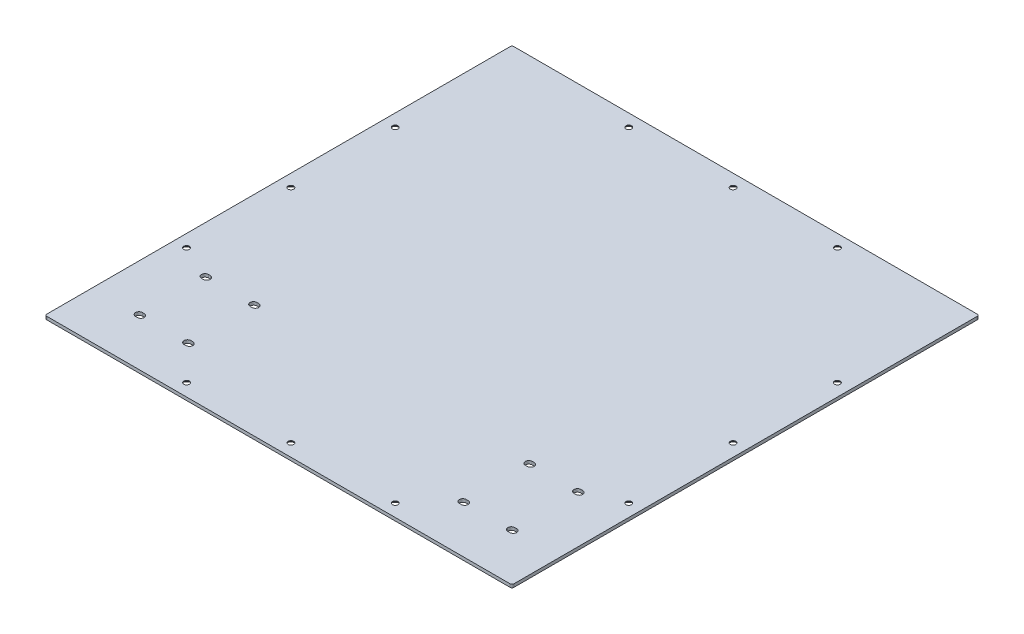
from build123d import *

# Parameters (mm, degrees)
SKETCH1_W                                      = 750
SKETCH1_H                                      = 750
BOSS_EXTRUDE1_DEPTH                            = 5
CSK_FOR_M8_FLAT_HEAD_MACHINE_SCREW1_AT_2_COUNT = 2
CSK_FOR_M8_FLAT_HEAD_MACHINE_SCREW1_AT_2_PITCH = 167.5
CSK_FOR_M8_FLAT_HEAD_MACHINE_SCREW1_AT_3_COUNT = 2
CSK_FOR_M8_FLAT_HEAD_MACHINE_SCREW1_AT_3_PITCH = 167.5
CSK_FOR_M8_FLAT_HEAD_MACHINE_SCREW1_AT_4_COUNT = 2
CSK_FOR_M8_FLAT_HEAD_MACHINE_SCREW1_AT_4_PITCH = 502.045814642
CSK_FOR_M8_FLAT_HEAD_MACHINE_SCREW1_AT_5_COUNT = 2
CSK_FOR_M8_FLAT_HEAD_MACHINE_SCREW1_AT_5_PITCH = 631.689203644
CSK_FOR_M8_FLAT_HEAD_MACHINE_SCREW1_AT_6_COUNT = 2
CSK_FOR_M8_FLAT_HEAD_MACHINE_SCREW1_AT_6_PITCH = 401.473847218
FILLET1_R                                      = 3
CUT_EXTRUDE1_DEPTH                             = 6
LPATTERN1_COUNT                                = 2
LPATTERN1_PITCH                                = 520


with BuildPart() as part:
    # Sketch1 → Boss-Extrude1 (new body)
    with BuildSketch(Plane(origin=(0, 0, 0), x_dir=(1, 0, 0), z_dir=(0, 1, 0))):
        with Locations((375, -375)):
            Rectangle(SKETCH1_W, SKETCH1_H)
    extrude(amount=BOSS_EXTRUDE1_DEPTH)

    # Sketch4 → CSK for M8 Flat Head Machine Screw1 (revolve, cut)
    with BuildSketch(Plane(origin=(20, 0, 375), x_dir=(0, 0, -1), z_dir=(1, 0, 0))):
        Polygon((0, 0), (0, 5), (4.5, 5), (4.5, 4.15), (8.65, 0), align=None)
    csk_for_m8_flat_head_machine_screw1 = revolve(axis=Axis((20, -6.35, 375), (0, 1, 0)), mode=Mode.SUBTRACT)

    # CSK for M8 Flat Head Machine Screw1 at 2: CSK for M8 Flat Head Machine Screw1 ×2
    with Locations(*[(0, 0, i * CSK_FOR_M8_FLAT_HEAD_MACHINE_SCREW1_AT_2_PITCH) for i in range(1, CSK_FOR_M8_FLAT_HEAD_MACHINE_SCREW1_AT_2_COUNT)]):
        add(csk_for_m8_flat_head_machine_screw1, mode=Mode.SUBTRACT)

    # CSK for M8 Flat Head Machine Screw1 at 3: CSK for M8 Flat Head Machine Screw1 ×2
    with Locations(*[(0, 0, -i * CSK_FOR_M8_FLAT_HEAD_MACHINE_SCREW1_AT_3_PITCH) for i in range(1, CSK_FOR_M8_FLAT_HEAD_MACHINE_SCREW1_AT_3_COUNT)]):
        add(csk_for_m8_flat_head_machine_screw1, mode=Mode.SUBTRACT)

    # CSK for M8 Flat Head Machine Screw1 at 4: CSK for M8 Flat Head Machine Screw1 ×2
    with Locations(*[Vector(0.707106781, 0, 0.707106781) * (i * CSK_FOR_M8_FLAT_HEAD_MACHINE_SCREW1_AT_4_PITCH) for i in range(1, CSK_FOR_M8_FLAT_HEAD_MACHINE_SCREW1_AT_4_COUNT)]):
        add(csk_for_m8_flat_head_machine_screw1, mode=Mode.SUBTRACT)

    # CSK for M8 Flat Head Machine Screw1 at 5: CSK for M8 Flat Head Machine Screw1 ×2
    with Locations(*[Vector(0.82714727, 0, 0.561985226) * (i * CSK_FOR_M8_FLAT_HEAD_MACHINE_SCREW1_AT_5_PITCH) for i in range(1, CSK_FOR_M8_FLAT_HEAD_MACHINE_SCREW1_AT_5_COUNT)]):
        add(csk_for_m8_flat_head_machine_screw1, mode=Mode.SUBTRACT)

    # CSK for M8 Flat Head Machine Screw1 at 6: CSK for M8 Flat Head Machine Screw1 ×2
    with Locations(*[Vector(0.467029176, 0, 0.884241906) * (i * CSK_FOR_M8_FLAT_HEAD_MACHINE_SCREW1_AT_6_PITCH) for i in range(1, CSK_FOR_M8_FLAT_HEAD_MACHINE_SCREW1_AT_6_COUNT)]):
        add(csk_for_m8_flat_head_machine_screw1, mode=Mode.SUBTRACT)

    # Mirror1: CSK for M8 Flat Head Machine Screw1 across plane
    add(csk_for_m8_flat_head_machine_screw1.mirror(Plane(origin=(375, 0, 0), x_dir=(0, 0, 1), z_dir=(1, 0, 0))), mode=Mode.SUBTRACT)

    # Mirror1 copy 1 sketch → Mirror1 copy 1 (revolve, cut)
    with BuildSketch(Plane(origin=(730, 0, 542.5), x_dir=(0, 0, -1), z_dir=(-1, 0, 0))):
        Polygon((0, 0), (0, -5), (4.5, -5), (4.5, -4.15), (8.65, 0), align=None)
    revolve(axis=Axis((730, -6.35, 542.5), (0, -1, 0)), mode=Mode.SUBTRACT)

    # Mirror1 copy 2 sketch → Mirror1 copy 2 (revolve, cut)
    with BuildSketch(Plane(origin=(730, 0, 207.5), x_dir=(0, 0, -1), z_dir=(-1, 0, 0))):
        Polygon((0, 0), (0, -5), (4.5, -5), (4.5, -4.15), (8.65, 0), align=None)
    revolve(axis=Axis((730, -6.35, 207.5), (0, -1, 0)), mode=Mode.SUBTRACT)

    # Mirror1 copy 3 sketch → Mirror1 copy 3 (revolve, cut)
    with BuildSketch(Plane(origin=(375, 0, 730), x_dir=(0, 0, -1), z_dir=(-1, 0, 0))):
        Polygon((0, 0), (0, -5), (4.5, -5), (4.5, -4.15), (8.65, 0), align=None)
    revolve(axis=Axis((375, -6.35, 730), (0, -1, 0)), mode=Mode.SUBTRACT)

    # Mirror1 copy 4 sketch → Mirror1 copy 4 (revolve, cut)
    with BuildSketch(Plane(origin=(207.5, 0, 730), x_dir=(0, 0, -1), z_dir=(-1, 0, 0))):
        Polygon((0, 0), (0, -5), (4.5, -5), (4.5, -4.15), (8.65, 0), align=None)
    revolve(axis=Axis((207.5, -6.35, 730), (0, -1, 0)), mode=Mode.SUBTRACT)

    # Mirror1 copy 5 sketch → Mirror1 copy 5 (revolve, cut)
    with BuildSketch(Plane(origin=(542.5, 0, 730), x_dir=(0, 0, -1), z_dir=(-1, 0, 0))):
        Polygon((0, 0), (0, -5), (4.5, -5), (4.5, -4.15), (8.65, 0), align=None)
    revolve(axis=Axis((542.5, -6.35, 730), (0, -1, 0)), mode=Mode.SUBTRACT)

    # Mirror2 copy 1 sketch → Mirror2 copy 1 (revolve, cut)
    with BuildSketch(Plane(origin=(730, 0, 375), x_dir=(0, 0, 1), z_dir=(-1, 0, 0))):
        Polygon((0, 0), (0, 5), (4.5, 5), (4.5, 4.15), (8.65, 0), align=None)
    revolve(axis=Axis((730, -6.35, 375), (0, 1, 0)), mode=Mode.SUBTRACT)

    # Mirror2 copy 2 sketch → Mirror2 copy 2 (revolve, cut)
    with BuildSketch(Plane(origin=(730, 0, 207.5), x_dir=(0, 0, 1), z_dir=(-1, 0, 0))):
        Polygon((0, 0), (0, 5), (4.5, 5), (4.5, 4.15), (8.65, 0), align=None)
    revolve(axis=Axis((730, -6.35, 207.5), (0, 1, 0)), mode=Mode.SUBTRACT)

    # Mirror2 copy 3 sketch → Mirror2 copy 3 (revolve, cut)
    with BuildSketch(Plane(origin=(730, 0, 542.5), x_dir=(0, 0, 1), z_dir=(-1, 0, 0))):
        Polygon((0, 0), (0, 5), (4.5, 5), (4.5, 4.15), (8.65, 0), align=None)
    revolve(axis=Axis((730, -6.35, 542.5), (0, 1, 0)), mode=Mode.SUBTRACT)

    # Mirror2 copy 4 sketch → Mirror2 copy 4 (revolve, cut)
    with BuildSketch(Plane(origin=(375, 0, 20), x_dir=(0, 0, 1), z_dir=(-1, 0, 0))):
        Polygon((0, 0), (0, 5), (4.5, 5), (4.5, 4.15), (8.65, 0), align=None)
    revolve(axis=Axis((375, -6.35, 20), (0, 1, 0)), mode=Mode.SUBTRACT)

    # Mirror2 copy 5 sketch → Mirror2 copy 5 (revolve, cut)
    with BuildSketch(Plane(origin=(207.5, 0, 20), x_dir=(0, 0, 1), z_dir=(-1, 0, 0))):
        Polygon((0, 0), (0, 5), (4.5, 5), (4.5, 4.15), (8.65, 0), align=None)
    revolve(axis=Axis((207.5, -6.35, 20), (0, 1, 0)), mode=Mode.SUBTRACT)

    # Mirror2 copy 6 sketch → Mirror2 copy 6 (revolve, cut)
    with BuildSketch(Plane(origin=(542.5, 0, 20), x_dir=(0, 0, 1), z_dir=(-1, 0, 0))):
        Polygon((0, 0), (0, 5), (4.5, 5), (4.5, 4.15), (8.65, 0), align=None)
    revolve(axis=Axis((542.5, -6.35, 20), (0, 1, 0)), mode=Mode.SUBTRACT)

    # Mirror2 copy 7 sketch → Mirror2 copy 7 (revolve, cut)
    with BuildSketch(Plane(origin=(20, 0, 375), x_dir=(0, 0, 1), z_dir=(1, 0, 0))):
        Polygon((0, 0), (0, -5), (4.5, -5), (4.5, -4.15), (8.65, 0), align=None)
    revolve(axis=Axis((20, -6.35, 375), (0, -1, 0)), mode=Mode.SUBTRACT)

    # Mirror2 copy 8 sketch → Mirror2 copy 8 (revolve, cut)
    with BuildSketch(Plane(origin=(20, 0, 207.5), x_dir=(0, 0, 1), z_dir=(1, 0, 0))):
        Polygon((0, 0), (0, -5), (4.5, -5), (4.5, -4.15), (8.65, 0), align=None)
    revolve(axis=Axis((20, -6.35, 207.5), (0, -1, 0)), mode=Mode.SUBTRACT)

    # Mirror2 copy 9 sketch → Mirror2 copy 9 (revolve, cut)
    with BuildSketch(Plane(origin=(20, 0, 542.5), x_dir=(0, 0, 1), z_dir=(1, 0, 0))):
        Polygon((0, 0), (0, -5), (4.5, -5), (4.5, -4.15), (8.65, 0), align=None)
    revolve(axis=Axis((20, -6.35, 542.5), (0, -1, 0)), mode=Mode.SUBTRACT)

    # Mirror2 copy 10 sketch → Mirror2 copy 10 (revolve, cut)
    with BuildSketch(Plane(origin=(375, 0, 20), x_dir=(0, 0, 1), z_dir=(1, 0, 0))):
        Polygon((0, 0), (0, -5), (4.5, -5), (4.5, -4.15), (8.65, 0), align=None)
    revolve(axis=Axis((375, -6.35, 20), (0, -1, 0)), mode=Mode.SUBTRACT)

    # Mirror2 copy 11 sketch → Mirror2 copy 11 (revolve, cut)
    with BuildSketch(Plane(origin=(542.5, 0, 20), x_dir=(0, 0, 1), z_dir=(1, 0, 0))):
        Polygon((0, 0), (0, -5), (4.5, -5), (4.5, -4.15), (8.65, 0), align=None)
    revolve(axis=Axis((542.5, -6.35, 20), (0, -1, 0)), mode=Mode.SUBTRACT)

    # Mirror2 copy 12 sketch → Mirror2 copy 12 (revolve, cut)
    with BuildSketch(Plane(origin=(207.5, 0, 20), x_dir=(0, 0, 1), z_dir=(1, 0, 0))):
        Polygon((0, 0), (0, -5), (4.5, -5), (4.5, -4.15), (8.65, 0), align=None)
    revolve(axis=Axis((207.5, -6.35, 20), (0, -1, 0)), mode=Mode.SUBTRACT)

    # Fillet1
    fillet1_edges = [part.edges().sort_by_distance(p)[0] for p in [
        (0, 2.5, 0),
        (750, 2.5, 0),
        (750, 2.5, 750),
        (0, 2.5, 750),
    ]]
    fillet(fillet1_edges, radius=FILLET1_R)

    # Sketch2 → Cut-Extrude1 (cut, through all)
    with BuildSketch(Plane.XZ):
        with BuildLine():
            Line((152.5, 668), (155.5, 668))
            ThreePointArc((155.5, 668), (161, 673.5), (155.5, 679))
            Line((155.5, 679), (152.5, 679))
            ThreePointArc((152.5, 679), (147, 673.5), (152.5, 668))
        make_face()
        with BuildLine():
            Line((74.5, 668), (77.5, 668))
            ThreePointArc((77.5, 668), (83, 673.5), (77.5, 679))
            Line((77.5, 679), (74.5, 679))
            ThreePointArc((74.5, 679), (69, 673.5), (74.5, 668))
        make_face()
        with BuildLine():
            Line((74.5, 562), (77.5, 562))
            ThreePointArc((77.5, 562), (83, 567.5), (77.5, 573))
            Line((77.5, 573), (74.5, 573))
            ThreePointArc((74.5, 573), (69, 567.5), (74.5, 562))
        make_face()
        with BuildLine():
            Line((152.5, 562), (155.5, 562))
            ThreePointArc((155.5, 562), (161, 567.5), (155.5, 573))
            Line((155.5, 573), (152.5, 573))
            ThreePointArc((152.5, 573), (147, 567.5), (152.5, 562))
        make_face()
    cut_extrude1 = extrude(amount=-CUT_EXTRUDE1_DEPTH, mode=Mode.SUBTRACT)

    # LPattern1: Cut-Extrude1 ×2
    with Locations(*[(i * LPATTERN1_PITCH, 0, 0) for i in range(1, LPATTERN1_COUNT)]):
        add(cut_extrude1, mode=Mode.SUBTRACT)


solid = part.part
